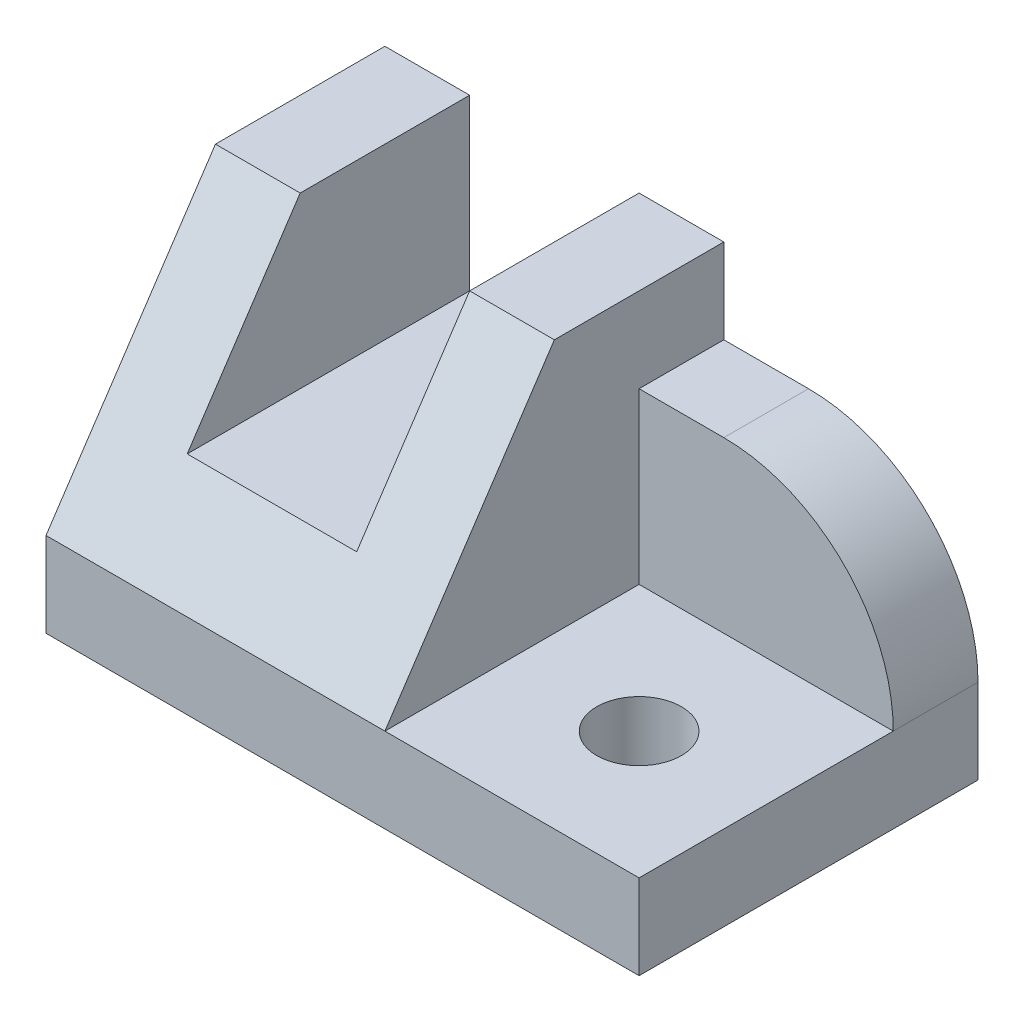
from build123d import *

# Parameters (mm, degrees)
SKETCH_1_W          = 15
SKETCH_1_H          = 15
SKETCH_1_R          = 2.5
EXTRUDE_1_DEPTH     = 5
SKETCH_1_3_W        = 15
SKETCH_1_3_H        = 5
EXTRUDE_2_DEPTH     = 15
EXTRUDE_3_DEPTH     = 20
CUT_EXTRUDE_1_DEPTH = 20
SKETCH_3_W          = 10
SKETCH_3_H          = 10
CUT_EXTRUDE_2_DEPTH = 20
FILLET_1_R          = 10


with BuildPart() as part:
    # 草圖1 → 填料-伸長1 (new body)
    with BuildSketch(Plane(origin=(0, 0, 0), x_dir=(1, 0, 0), z_dir=(0, 1, 0))):
        with Locations((10, -2.5)):
            Rectangle(SKETCH_1_W, SKETCH_1_H)
        with Locations((10, -2.5)):
            Circle(SKETCH_1_R, mode=Mode.SUBTRACT)
    extrude(amount=EXTRUDE_1_DEPTH)

    # 草圖1<3> → 填料-伸長2 (add)
    with BuildSketch(Plane(origin=(0, 0, 0), x_dir=(1, 0, 0), z_dir=(0, 1, 0))):
        with Locations((10, 7.5)):
            Rectangle(SKETCH_1_3_W, SKETCH_1_3_H)
    extrude(amount=EXTRUDE_2_DEPTH)

    # 草圖1<4> → 填料-伸長3 (add)
    with BuildSketch(Plane(origin=(0, 0, 0), x_dir=(1, 0, 0), z_dir=(0, 1, 0))):
        Polygon((-17.5, 10), (-17.5, -10), (2.5, -10), (2.5, 5), (2.5, 10), align=None)
    extrude(amount=EXTRUDE_3_DEPTH)

    # 草圖2 → 除料-伸長1 (cut)
    with BuildSketch(Plane(origin=(2.5, 0, 0), x_dir=(0, 0, -1), z_dir=(1, 0, 0))):
        Polygon((-10, 5), (0, 20), (-10, 20), align=None)
    extrude(amount=-CUT_EXTRUDE_1_DEPTH, mode=Mode.SUBTRACT)

    # 草圖3 → 除料-伸長2 (cut)
    with BuildSketch(Plane(origin=(0, 0, -10), x_dir=(-1, 0, 0), z_dir=(0, 0, -1))):
        with Locations((7.5, 15)):
            Rectangle(SKETCH_3_W, SKETCH_3_H)
    extrude(amount=-CUT_EXTRUDE_2_DEPTH, mode=Mode.SUBTRACT)

    # 圓角1
    fillet_1_edges = [part.edges().sort_by_distance(p)[0] for p in [
        (17.5, 15, -7.5),
    ]]
    fillet(fillet_1_edges, radius=FILLET_1_R)


solid = part.part
